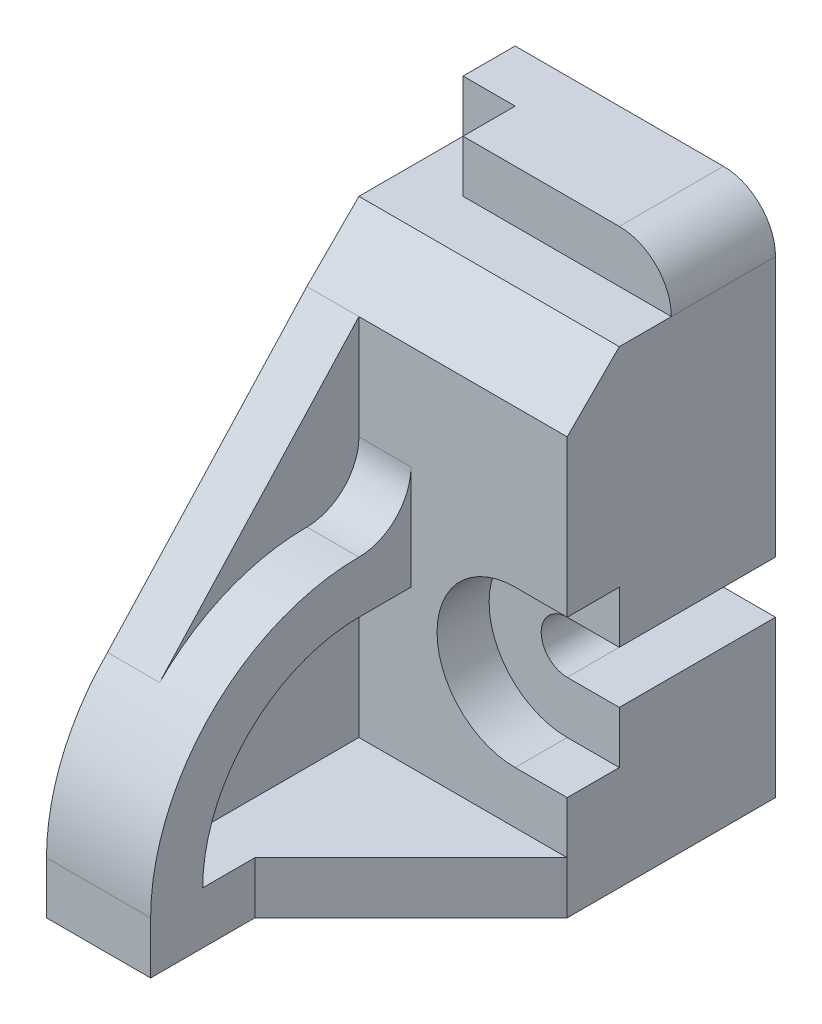
from build123d import *

# Parameters (mm, degrees)
BOSS_EXTRUDE1_DEPTH = 4
CUT_EXTRUDE1_DEPTH  = 1
SKETCH3_W           = 1
SKETCH3_H           = 1
CUT_EXTRUDE2_DEPTH  = 3
SKETCH4_W           = 2
SKETCH4_H           = 1
CUT_EXTRUDE4_DEPTH  = 6
CUT_EXTRUDE5_DEPTH  = 6
BOSS_EXTRUDE2_DEPTH = 1
BOSS_EXTRUDE3_DEPTH = 2
BOSS_EXTRUDE4_DEPTH = 1


with BuildPart() as part:
    # Sketch1 → Boss-Extrude1 (new body)
    with BuildSketch(Plane.XY):
        with BuildLine():
            Line((0, 9), (5, 9))
            ThreePointArc((5, 9), (4.707106781, 9.707106781), (4, 10))
            Line((4, 10), (0, 10))
            Line((0, 10), (0, 9))
        make_face()
        with BuildLine():
            ThreePointArc((4, 4), (3.5, 3.5), (4, 3))
            Line((4, 3), (5, 3))
            Line((5, 3), (5, 0))
            Line((5, 0), (0, 0))
            Line((0, 0), (0, 9))
            Line((0, 9), (5, 9))
            Line((5, 9), (5, 4))
            Line((5, 4), (4, 4))
        make_face()
    extrude(amount=BOSS_EXTRUDE1_DEPTH)

    # Sketch2 → Cut-Extrude1 (cut)
    with BuildSketch(Plane.XY.offset(4)):
        with BuildLine():
            Line((5, 3), (5, 2))
            Line((5, 2), (4, 2))
            ThreePointArc((4, 2), (2.5, 3.5), (4, 5))
            Line((4, 5), (5, 5))
            Line((5, 5), (5, 4))
            Line((5, 4), (4, 4))
            ThreePointArc((4, 4), (3.5, 3.5), (4, 3))
            Line((4, 3), (5, 3))
        make_face()
    extrude(amount=-CUT_EXTRUDE1_DEPTH, mode=Mode.SUBTRACT)

    # Sketch3 → Cut-Extrude2 (cut)
    with BuildSketch(Plane.XY.offset(4)):
        with Locations((0.5, 9.5)):
            Rectangle(SKETCH3_W, SKETCH3_H)
    extrude(amount=-CUT_EXTRUDE2_DEPTH, mode=Mode.SUBTRACT)

    # Sketch4 → Cut-Extrude4 (cut, through all)
    with BuildSketch(Plane.ZY):
        with Locations((3, 9.5)):
            Rectangle(SKETCH4_W, SKETCH4_H)
    extrude(amount=-CUT_EXTRUDE4_DEPTH, mode=Mode.SUBTRACT)

    # Sketch5 → Cut-Extrude5 (cut, through all)
    with BuildSketch(Plane(origin=(5, 0, 0), x_dir=(0, 0, -1), z_dir=(1, 0, 0))):
        Polygon((-3, 9), (-4, 8), (-4, 9), align=None)
    extrude(amount=-CUT_EXTRUDE5_DEPTH, mode=Mode.SUBTRACT)

    # Sketch6 → Boss-Extrude2 (add)
    with BuildSketch(Plane.XZ):
        Polygon((0, 4), (0, 9), (2, 9), (2, 7), (5, 4), align=None)
    extrude(amount=-BOSS_EXTRUDE2_DEPTH)

    # Sketch7 → Boss-Extrude3 (add)
    with BuildSketch(Plane.ZY):
        with BuildLine():
            Line((8, 1), (9, 1))
            ThreePointArc((9, 1), (7.828427125, 3.828427125), (5, 5))
            ThreePointArc((5, 5), (4.292893219, 5.292893219), (4, 6))
            Line((4, 6), (4, 4))
            Line((4, 4), (5, 4))
            ThreePointArc((5, 4), (7.121320344, 3.121320344), (8, 1))
        make_face()
    extrude(amount=-BOSS_EXTRUDE3_DEPTH)

    # Sketch9 → Boss-Extrude4 (add)
    with BuildSketch(Plane.ZY):
        Polygon((4, 8), (7.828427125, 3.828427125), (8, 1), (4, 1), align=None)
    extrude(amount=-BOSS_EXTRUDE4_DEPTH)


solid = part.part
